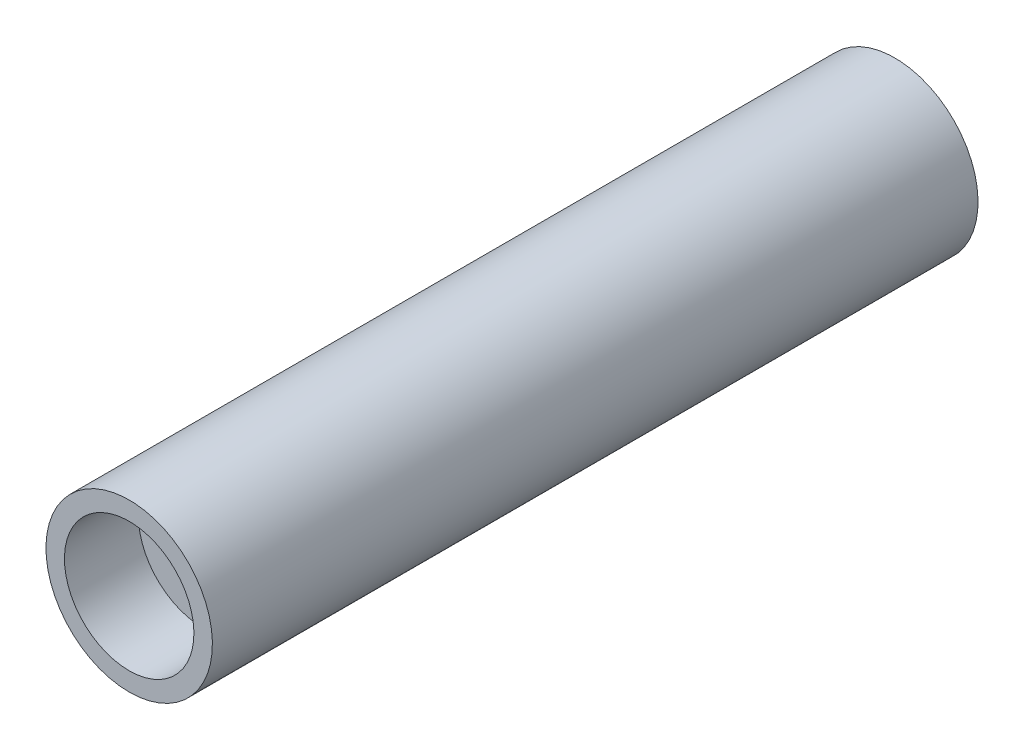
from build123d import *

# Parameters (mm, degrees)
SCALE1_SCALE = 0.6


with BuildPart() as part:
    # Sketch1 → Revolve1 (revolve)
    with BuildSketch(Plane(origin=(0, 0, 0), x_dir=(0, 0, -1), z_dir=(1, 0, 0))):
        Polygon((16.7, 3.5), (20.7, 3.5), (20.7, 4.5), (-20.7, 4.5), (-20.7, 3.5), (-16.7, 3.5), (-16.7, 2), (16.7, 2), align=None)
    revolve(axis=Axis((0, 0, 16.930047934), (0, 0, -1)))


with BuildPart() as part_1:
    # Scale1: scaled about (0, 0, 0)
    add(part.part.scale(SCALE1_SCALE))


solid = part_1.part
